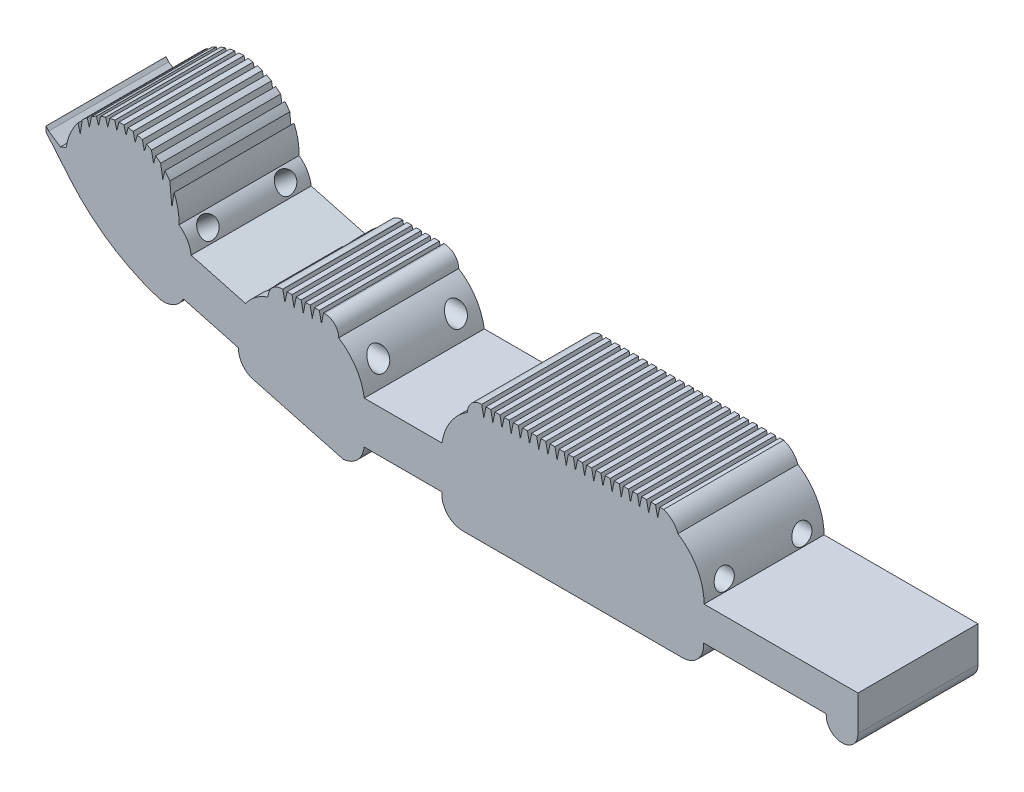
from build123d import *

# Parameters (mm, degrees)
BOSS_EXTRUDE1_DEPTH     = 17
CUT_EXTRUDE1_DEPTH      = 40
CUT_EXTRUDE1_DEPTH_BACK = 12
SKETCH2_R               = 1.4
SKETCH3_R               = 1.4
CUT_EXTRUDE2_DEPTH      = 42
SKETCH4_R               = 1.4
CUT_EXTRUDE3_DEPTH      = 12
CUT_EXTRUDE4_DEPTH      = 12
CUT_EXTRUDE4_DEPTH_BACK = 12
SKETCH5_R               = 1.4


with BuildPart() as part:
    # Sketch1 → Boss-Extrude1 (new body)
    with BuildSketch(Plane.XY):
        with BuildLine():
            Line((-43.113594231, 12.057000798), (-43.41685156, 13.562681784))
            ThreePointArc((-43.41685156, 13.562681784), (-44.254829992, 13.388801387), (-44.942664298, 12.879560568))
            ThreePointArc((-44.942664298, 12.879560568), (-45.30194863, 12.277263859), (-45.427012921, 11.587187429))
            ThreePointArc((-45.427012921, 11.587187429), (-47.850168222, 9.189861051), (-49.051684702, 6))
            Line((-49.051684702, 6), (-60.051684702, 6))
            ThreePointArc((-60.051684702, 6), (-61.253201182, 9.18986105), (-63.676356482, 11.587187427))
            ThreePointArc((-63.676356482, 11.587187427), (-64.26214292, 13.001400989), (-65.676356482, 13.587187427))
            Line((-65.676356482, 13.587187427), (-65.818512813, 13.587152417))
            Line((-65.818512813, 13.587152417), (-66.118512813, 12.087152417))
            Line((-66.118512813, 12.087152417), (-66.418512813, 13.587152417))
            Line((-66.418512813, 13.587152417), (-67.118512813, 13.587152417))
            Line((-67.118512813, 13.587152417), (-67.418512813, 12.087152417))
            Line((-67.418512813, 12.087152417), (-67.718512813, 13.587152417))
            Line((-67.718512813, 13.587152417), (-68.392502802, 13.587152417))
            Line((-68.392502802, 13.587152417), (-68.692502802, 12.087152417))
            Line((-68.692502802, 12.087152417), (-68.992502802, 13.587152417))
            Line((-68.992502802, 13.587152417), (-69.692502802, 13.587152417))
            Line((-69.692502802, 13.587152417), (-69.992502802, 12.087152417))
            Line((-69.992502802, 12.087152417), (-70.292502802, 13.587152417))
            Line((-70.292502802, 13.587152417), (-70.992502802, 13.587152417))
            Line((-70.992502802, 13.587152417), (-71.292502802, 12.087152417))
            Line((-71.292502802, 12.087152417), (-71.592502802, 13.587152417))
            Line((-71.592502802, 13.587152417), (-71.676356482, 13.587187427))
            ThreePointArc((-71.676356482, 13.587187427), (-73.090570045, 13.001400989), (-73.676356482, 11.587187427))
            ThreePointArc((-73.676356482, 11.587187427), (-75.462169176, 10.657633974), (-76.850977721, 9.200099267))
            Line((-76.850977721, 9.200099267), (-84.577579491, 11.273653002))
            ThreePointArc((-84.577579491, 11.273653002), (-85.130495095, 12.890872002), (-86.302468939, 14.134893815))
            ThreePointArc((-86.302468939, 14.134893815), (-86.441268893, 15.989467967), (-87.002468939, 17.762534583))
            Line((-87.002468939, 17.762534583), (-87.302468939, 15.762534583))
            Line((-87.302468939, 15.762534583), (-87.602468939, 18.859996813))
            ThreePointArc((-87.602468939, 18.859996813), (-87.935897525, 19.332846831), (-88.302468939, 19.780493076))
            Line((-88.302468939, 19.780493076), (-88.602468939, 18.580493076))
            Line((-88.602468939, 18.580493076), (-88.902468939, 20.392529047))
            ThreePointArc((-88.902468939, 20.392529047), (-89.244409119, 20.688740953), (-89.602468939, 20.96525089))
            Line((-89.602468939, 20.96525089), (-89.902468939, 19.86525089))
            Line((-89.902468939, 19.86525089), (-90.202468939, 21.362383265))
            ThreePointArc((-90.202468939, 21.362383265), (-90.547853269, 21.557959256), (-90.902468939, 21.736251238))
            Line((-90.902468939, 21.736251238), (-91.202468939, 20.736251238))
            Line((-91.202468939, 20.736251238), (-91.502468939, 21.990383468))
            ThreePointArc((-91.502468939, 21.990383468), (-91.849863317, 22.11218232), (-92.202468939, 22.217951362))
            Line((-92.202468939, 22.217951362), (-92.502468939, 21.167951362))
            Line((-92.502468939, 21.167951362), (-92.802468939, 22.3585602))
            ThreePointArc((-92.802468939, 22.3585602), (-93.151321369, 22.418387941), (-93.502468939, 22.462803722))
            Line((-93.502468939, 22.462803722), (-93.802468939, 21.362803722))
            Line((-93.802468939, 21.362803722), (-94.102468939, 22.502702907))
            ThreePointArc((-94.102468939, 22.502702907), (-94.453207361, 22.505221723), (-94.80372188, 22.492440559))
            Line((-94.80372188, 22.492440559), (-95.10372188, 21.30183172))
            Line((-95.10372188, 21.30183172), (-95.40372188, 22.43481024))
            ThreePointArc((-95.40372188, 22.43481024), (-95.75400097, 22.379969596), (-96.101521688, 22.309739348))
            Line((-96.101521688, 22.309739348), (-96.401521688, 21.052626673))
            Line((-96.401521688, 21.052626673), (-96.701521688, 22.150077213))
            ThreePointArc((-96.701521688, 22.150077213), (-97.054165683, 22.032502704), (-97.400998119, 21.898753635))
            Line((-97.400998119, 21.898753635), (-97.700998119, 20.598753635))
            Line((-97.700998119, 20.598753635), (-98.000998119, 21.621921495))
            ThreePointArc((-98.000998119, 21.621921495), (-98.355127821, 21.429164643), (-98.699148769, 21.218896631))
            Line((-98.699148769, 21.218896631), (-98.999148769, 19.718896631))
            Line((-98.999148769, 19.718896631), (-99.299148769, 20.790963939))
            ThreePointArc((-99.299148769, 20.790963939), (-99.65894924, 20.491264542), (-100.000691448, 20.171126493))
            Line((-100.000691448, 20.171126493), (-100.300691448, 18.271126493))
            Line((-100.300691448, 18.271126493), (-100.600691448, 19.504858553))
            ThreePointArc((-100.600691448, 19.504858553), (-101.70426212, 17.682147833), (-102.290277245, 15.633555909))
            ThreePointArc((-102.290277245, 15.633555909), (-102.697090144, 15.467187125), (-103.099659894, 15.290798622))
            Line((-103.099659894, 15.290798622), (-104.757422328, 16.409647902))
            Line((-104.757422328, 16.409647902), (-105.143099665, 16.850305593))
            Line((-105.143099665, 16.850305593), (-105.143099665, 16.114164331))
            Line((-105.143099665, 16.114164331), (-101.845601059, 12.170427828))
            ThreePointArc((-101.845601059, 12.170427828), (-96.139026174, 7.042164201), (-89.221904394, 3.722900573))
            ThreePointArc((-89.221904394, 3.722900573), (-87.170107285, 3.905257652), (-85.719579902, 5.367822451))
            Line((-85.719579902, 5.367822451), (-77.878944639, 3.263666056))
            ThreePointArc((-77.878944639, 3.263666056), (-77.256090002, 1.403484439), (-75.584910789, 0.376165802))
            Line((-75.584910789, 0.376165802), (-63.029182913, -2.993359017))
            ThreePointArc((-63.029182913, -2.993359017), (-61.011447313, -2.032549949), (-60.082387724, 0))
            Line((-60.082387724, 0), (-49.056005233, 0))
            ThreePointArc((-49.056005233, 0), (-48.285248026, -2.334659895), (-46.028002616, -3.309106743))
            Line((-46.028002616, -3.309106743), (-15.028002616, -3.309106743))
            ThreePointArc((-15.028002616, -3.309106743), (-12.770757207, -2.334659895), (-12, 0))
            Line((-12, 0), (0, 0))
            Line((0, 0), (5.39540601, 0))
            Line((5.39540601, 0), (5.39540601, -0.2))
            ThreePointArc((5.39540601, -0.2), (7.64540601, -2.45), (9.89540601, -0.2))
            Line((9.89540601, -0.2), (9.89540601, 4.8))
            Line((9.89540601, 4.8), (5.39540601, 4.8))
            Line((5.39540601, 4.8), (0, 4.8))
            Line((0, 4.8), (-11.916444412, 4.8))
            ThreePointArc((-11.916444412, 4.8), (-12.893220694, 8.672933089), (-15.624671639, 11.587187429))
            ThreePointArc((-15.624671639, 11.587187429), (-16.404743298, 12.801712029), (-17.634833, 13.557000799))
            Line((-17.634833, 13.557000799), (-18.188366933, 13.557000799))
            Line((-18.188366933, 13.557000799), (-18.488366933, 12.057000798))
            Line((-18.488366933, 12.057000798), (-18.788366933, 13.557000798))
            Line((-18.788366933, 13.557000798), (-19.462356923, 13.557000798))
            Line((-19.462356923, 13.557000798), (-19.762356923, 12.057000798))
            Line((-19.762356923, 12.057000798), (-20.062356923, 13.557000798))
            Line((-20.062356923, 13.557000798), (-20.762356923, 13.557000798))
            Line((-20.762356923, 13.557000798), (-21.062356923, 12.057000798))
            Line((-21.062356923, 12.057000798), (-21.362356923, 13.557000798))
            Line((-21.362356923, 13.557000798), (-22.036346912, 13.557000798))
            Line((-22.036346912, 13.557000798), (-22.336346912, 12.057000798))
            Line((-22.336346912, 12.057000798), (-22.636346912, 13.557000798))
            Line((-22.636346912, 13.557000798), (-23.336346912, 13.557000798))
            Line((-23.336346912, 13.557000798), (-23.636346912, 12.057000798))
            Line((-23.636346912, 12.057000798), (-23.936346912, 13.557000798))
            Line((-23.936346912, 13.557000798), (-24.636346912, 13.557000798))
            Line((-24.636346912, 13.557000798), (-24.936346912, 12.057000798))
            Line((-24.936346912, 12.057000798), (-25.236346912, 13.557000798))
            Line((-25.236346912, 13.557000798), (-25.936346912, 13.557000798))
            Line((-25.936346912, 13.557000798), (-26.236346912, 12.057000798))
            Line((-26.236346912, 12.057000798), (-26.536346912, 13.557000798))
            Line((-26.536346912, 13.557000798), (-27.236346912, 13.557000798))
            Line((-27.236346912, 13.557000798), (-27.536346912, 12.057000798))
            Line((-27.536346912, 12.057000798), (-27.836346912, 13.557000798))
            Line((-27.836346912, 13.557000798), (-28.536346912, 13.557000798))
            Line((-28.536346912, 13.557000798), (-28.836346912, 12.057000798))
            Line((-28.836346912, 12.057000798), (-29.136346912, 13.557000798))
            Line((-29.136346912, 13.557000798), (-29.836346912, 13.557000798))
            Line((-29.836346912, 13.557000798), (-30.136346912, 12.057000798))
            Line((-30.136346912, 12.057000798), (-30.436346912, 13.557000798))
            Line((-30.436346912, 13.557000798), (-31.136346912, 13.557000798))
            Line((-31.136346912, 13.557000798), (-31.436346912, 12.057000798))
            Line((-31.436346912, 12.057000798), (-31.736346912, 13.557000798))
            Line((-31.736346912, 13.557000798), (-32.436346912, 13.557000798))
            Line((-32.436346912, 13.557000798), (-32.736346912, 12.057000798))
            Line((-32.736346912, 12.057000798), (-33.036346912, 13.557000798))
            Line((-33.036346912, 13.557000798), (-33.736346912, 13.557000798))
            Line((-33.736346912, 13.557000798), (-34.036346912, 12.057000798))
            Line((-34.036346912, 12.057000798), (-34.336346912, 13.557000798))
            Line((-34.336346912, 13.557000798), (-35.036346912, 13.557000798))
            Line((-35.036346912, 13.557000798), (-35.336346912, 12.057000798))
            Line((-35.336346912, 12.057000798), (-35.636346912, 13.557000798))
            Line((-35.636346912, 13.557000798), (-36.336346912, 13.557000798))
            Line((-36.336346912, 13.557000798), (-36.636346912, 12.057000798))
            Line((-36.636346912, 12.057000798), (-36.936346912, 13.557000798))
            Line((-36.936346912, 13.557000798), (-37.636346912, 13.557000798))
            Line((-37.636346912, 13.557000798), (-37.936346912, 12.057000798))
            Line((-37.936346912, 12.057000798), (-38.236346912, 13.557000798))
            Line((-38.236346912, 13.557000798), (-38.936346912, 13.557000798))
            Line((-38.936346912, 13.557000798), (-39.236346912, 12.057000798))
            Line((-39.236346912, 12.057000798), (-39.536346912, 13.557000798))
            Line((-39.536346912, 13.557000798), (-40.236346912, 13.557000798))
            Line((-40.236346912, 13.557000798), (-40.536346912, 12.057000798))
            Line((-40.536346912, 12.057000798), (-40.836346912, 13.557000798))
            Line((-40.836346912, 13.557000798), (-41.536346912, 13.557000798))
            Line((-41.536346912, 13.557000798), (-41.836346912, 12.057000798))
            Line((-41.836346912, 12.057000798), (-42.136346912, 13.557000798))
            Line((-42.136346912, 13.557000798), (-42.810336902, 13.557000798))
            Line((-42.810336902, 13.557000798), (-43.113594231, 12.057000798))
        make_face()
    extrude(amount=BOSS_EXTRUDE1_DEPTH)

    # Sketch2 → Cut-Extrude1 (cut, two sides: drawn at the far end of the back side and taken through both)
    with BuildSketch(Plane(origin=(-60, 0, 0), x_dir=(0, 0, -1), z_dir=(1, 0, 0)).offset(-CUT_EXTRUDE1_DEPTH_BACK)):
        with Locations((-14, 8.793593713)):
            Circle(SKETCH2_R)
        with Locations((-3, 8.793593713)):
            Circle(SKETCH2_R)
    extrude(amount=CUT_EXTRUDE1_DEPTH + CUT_EXTRUDE1_DEPTH_BACK, mode=Mode.SUBTRACT)

    # Sketch3 → Cut-Extrude2 (cut)
    with BuildSketch(Plane(origin=(0, 0, 0), x_dir=(0, 0, -1), z_dir=(1, 0, 0))):
        with Locations((-14, 6.3)):
            Circle(SKETCH3_R)
        with Locations((-3, 6.3)):
            Circle(SKETCH3_R)
    extrude(amount=-CUT_EXTRUDE2_DEPTH, mode=Mode.SUBTRACT)

    # Sketch4 → Cut-Extrude3 (cut)
    with BuildSketch(Plane(origin=(-70.801515891, 25.800793123, 0), x_dir=(0, 0, -1), z_dir=(0.9395597001849917, -0.342385119110467, 0))):
        with Locations((-3, -16.003711198)):
            Circle(SKETCH4_R)
        with Locations((-14, -16.003711198)):
            Circle(SKETCH4_R)
    extrude(amount=CUT_EXTRUDE3_DEPTH, mode=Mode.SUBTRACT)

    # Sketch5 → Cut-Extrude4 (cut, two sides: drawn at the far end of the back side and taken through both)
    with BuildSketch(Plane(origin=(-44.114083521, -36.986921032, 0), x_dir=(0, 0, -1), z_dir=(0.7662940611199175, 0.6424900091770643, 0)).offset(-CUT_EXTRUDE4_DEPTH_BACK)):
        with Locations((-14, 64.629571205)):
            Circle(SKETCH5_R)
        with Locations((-3, 64.629571205)):
            Circle(SKETCH5_R)
    extrude(amount=CUT_EXTRUDE4_DEPTH + CUT_EXTRUDE4_DEPTH_BACK, mode=Mode.SUBTRACT)


solid = part.part
